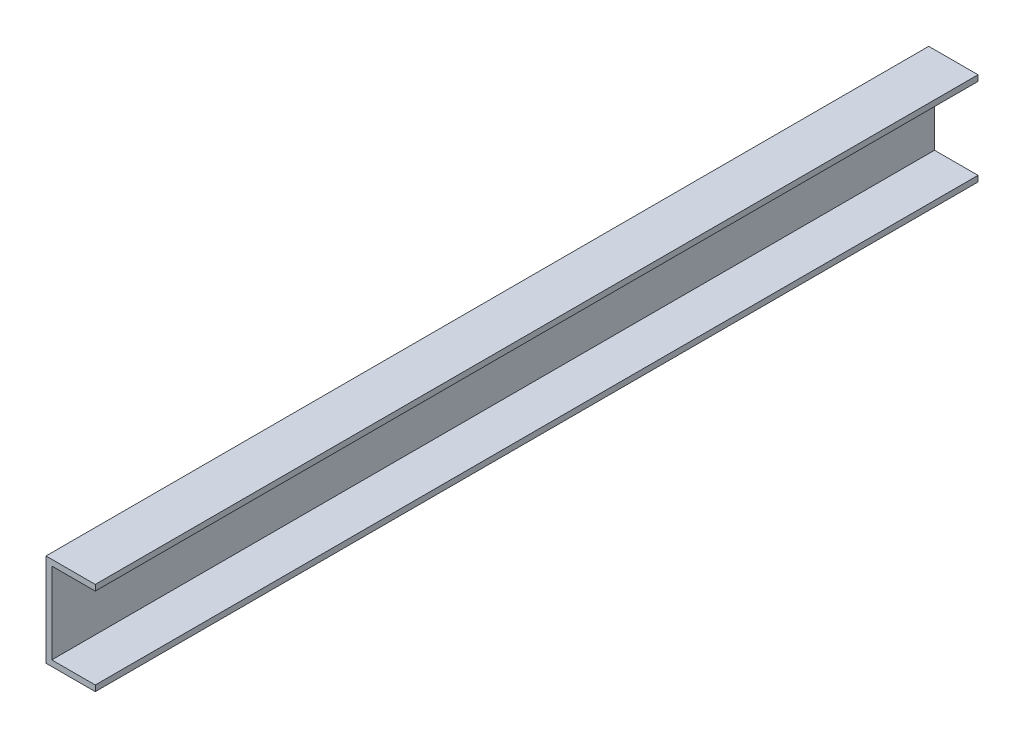
from build123d import *

# Parameters (mm, degrees)
BOSS_EXTRUDE1_DEPTH = 241.3


with BuildPart() as part:
    # Sketch1 → Boss-Extrude1 (new body, symmetric)
    with BuildSketch(Plane.XY):
        Polygon((0, 0), (26.931015876, 0), (26.931015876, 3.175), (3.175, 3.175), (3.175, 47.625), (26.931015876, 47.625), (26.931015876, 50.8), (0, 50.8), align=None)
    extrude(amount=BOSS_EXTRUDE1_DEPTH, both=True)


solid = part.part
